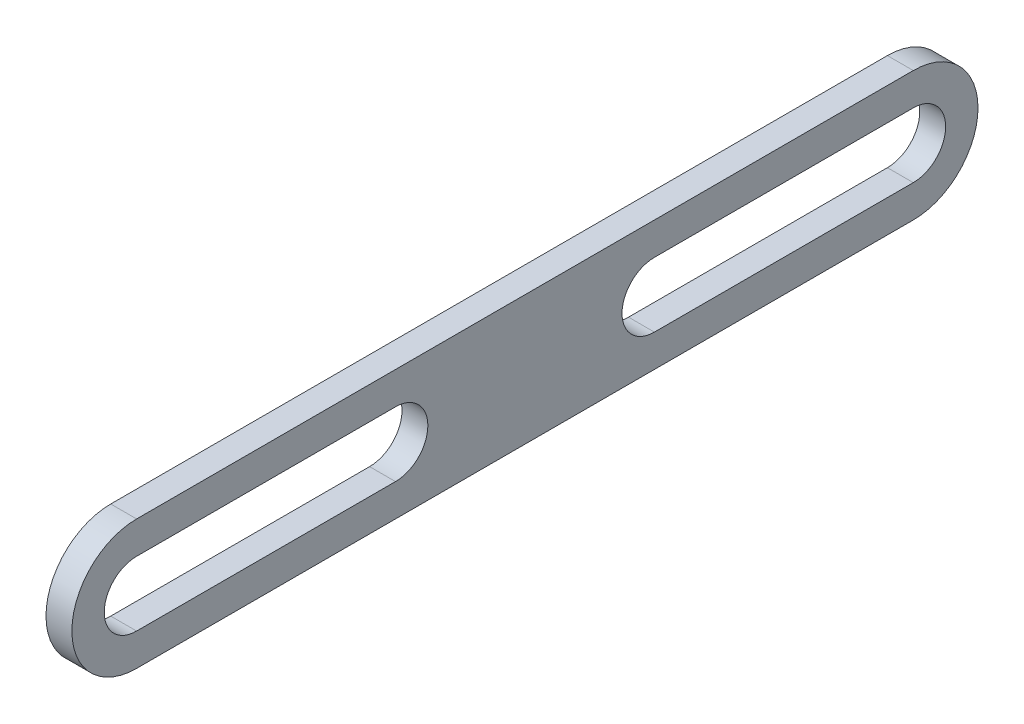
from build123d import *

# Parameters (mm, degrees)
BOSS_EXTRUDE1_DEPTH = 1.27
CUT_EXTRUDE1_DEPTH  = 3.54


with BuildPart() as part:
    # Sketch1 → Boss-Extrude1 (new body, symmetric)
    with BuildSketch(Plane(origin=(0, 0, 0), x_dir=(0, 0, -1), z_dir=(1, 0, 0))):
        with BuildLine():
            Line((-38.1, 6.35), (38.1, 6.35))
            ThreePointArc((38.1, 6.35), (44.45, 0), (38.1, -6.35))
            Line((38.1, -6.35), (-38.1, -6.35))
            ThreePointArc((-38.1, -6.35), (-44.45, 0), (-38.1, 6.35))
        make_face()
    extrude(amount=BOSS_EXTRUDE1_DEPTH, both=True)

    # Sketch2 → Cut-Extrude1 (cut, through all)
    with BuildSketch(Plane(origin=(1.27, 0, 0), x_dir=(0, 0, -1), z_dir=(1, 0, 0))):
        with BuildLine():
            Line((-38.1, 3.175), (-12.7, 3.175))
            ThreePointArc((-12.7, 3.175), (-9.525, 0), (-12.7, -3.175))
            Line((-12.7, -3.175), (-38.1, -3.175))
            ThreePointArc((-38.1, -3.175), (-41.275, 0), (-38.1, 3.175))
        make_face()
        with BuildLine():
            Line((38.1, 3.175), (12.7, 3.175))
            ThreePointArc((12.7, 3.175), (9.525, 0), (12.7, -3.175))
            Line((12.7, -3.175), (38.1, -3.175))
            ThreePointArc((38.1, -3.175), (41.275, 0), (38.1, 3.175))
        make_face()
    extrude(amount=-CUT_EXTRUDE1_DEPTH, mode=Mode.SUBTRACT)


solid = part.part
